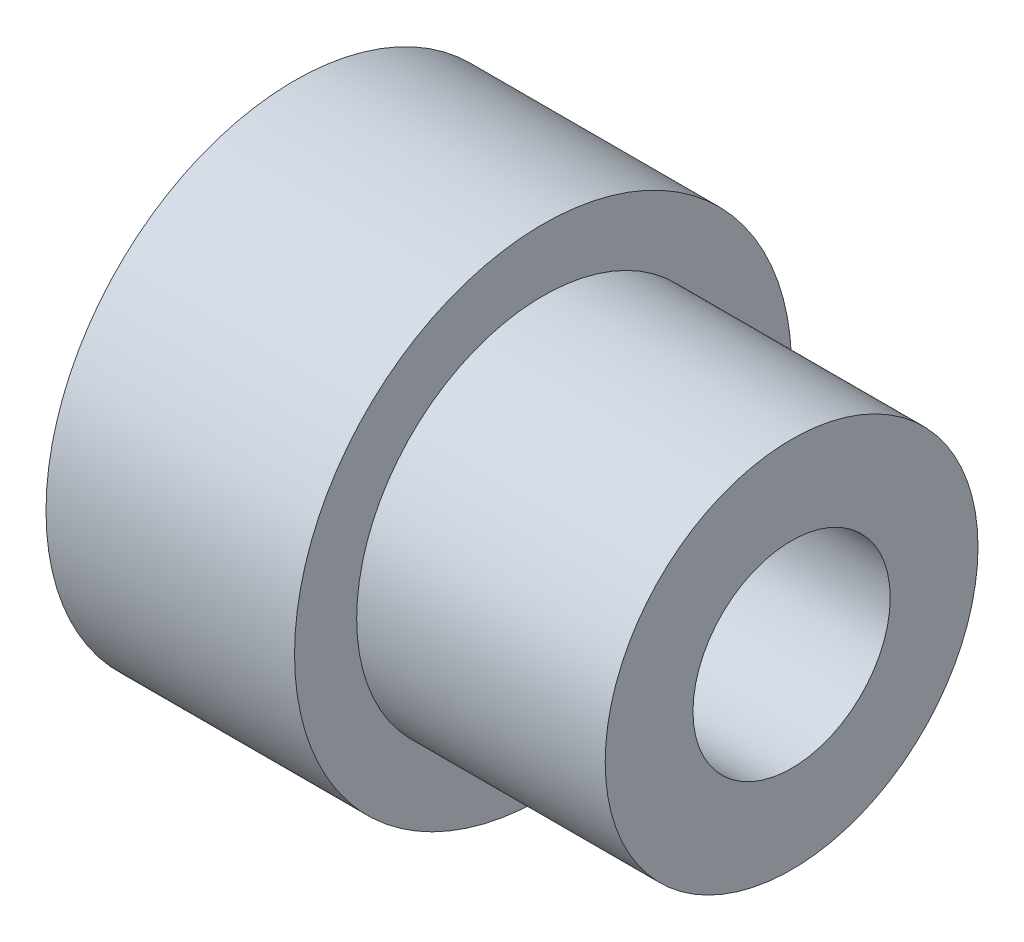
from build123d import *

# Parameters (mm, degrees)
SKETCH2_R           = 5.999999938
BOSS_EXTRUDE1_DEPTH = 8.000000002
SKETCH3_R           = 8.000000002
BOSS_EXTRUDE2_DEPTH = 8.000000002
SKETCH4_R           = 3.175
CUT_EXTRUDE1_DEPTH  = 17.000000004


with BuildPart() as part:
    # Sketch2 → Boss-Extrude1 (new body)
    with BuildSketch(Plane(origin=(0, 0, 0), x_dir=(0, 0, -1), z_dir=(1, 0, 0))):
        Circle(SKETCH2_R)
    extrude(amount=BOSS_EXTRUDE1_DEPTH)

    # Sketch3 → Boss-Extrude2 (add)
    with BuildSketch(Plane.ZY):
        Circle(SKETCH3_R)
    extrude(amount=BOSS_EXTRUDE2_DEPTH)

    # Sketch4 → Cut-Extrude1 (cut, through all)
    with BuildSketch(Plane(origin=(8.000000002, 0, 0), x_dir=(0, 0, -1), z_dir=(1, 0, 0))):
        Circle(SKETCH4_R)
    extrude(amount=-CUT_EXTRUDE1_DEPTH, mode=Mode.SUBTRACT)


solid = part.part
